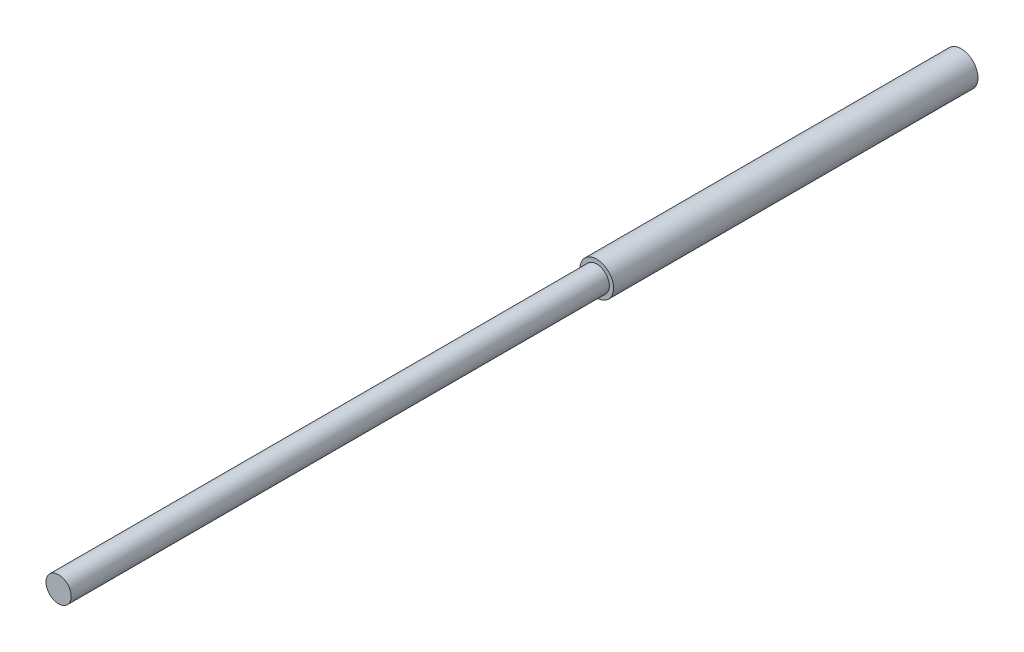
from build123d import *

# Parameters (mm, degrees)
SKETCH1_R           = 5
BOSS_EXTRUDE1_DEPTH = 108.36
SKETCH2_R           = 3.75
BOSS_EXTRUDE2_DEPTH = 160


with BuildPart() as part:
    # Sketch1 → Boss-Extrude1 (new body)
    with BuildSketch(Plane.XY):
        Circle(SKETCH1_R)
    extrude(amount=BOSS_EXTRUDE1_DEPTH)

    # Sketch2 → Boss-Extrude2 (add)
    with BuildSketch(Plane.XY.offset(108.36)):
        Circle(SKETCH2_R)
    extrude(amount=BOSS_EXTRUDE2_DEPTH)


solid = part.part
